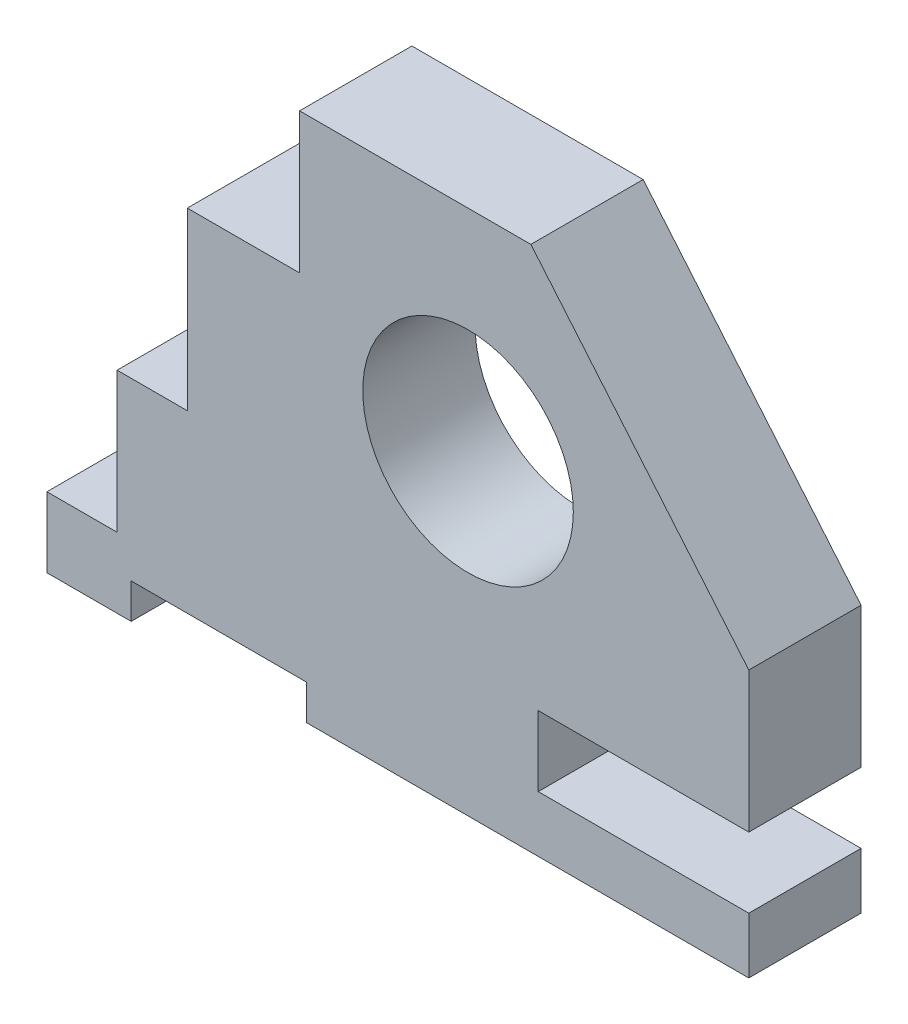
from build123d import *

# Parameters (mm, degrees)
SKETCH2_R           = 15
BOSS_EXTRUDE1_DEPTH = 16


with BuildPart() as part:
    # Sketch2 → Boss-Extrude1 (new body)
    with BuildSketch(Plane.XY):
        Polygon((18.953313646, 37.5), (50, 0.5), (50, -19.5), (20, -19.5), (20, -29.5), (50, -29.5), (50, -37.5), (-13, -37.5), (-13, -32.5), (-38, -32.5), (-38, -37.5), (-50, -37.5), (-50, -27.5), (-40, -27.5), (-40, -7.5), (-30, -7.5), (-30, 17.5), (-14, 17.5), (-14, 37.5), align=None)
        with Locations((10, 7.5)):
            Circle(SKETCH2_R, mode=Mode.SUBTRACT)
    extrude(amount=BOSS_EXTRUDE1_DEPTH)


solid = part.part
